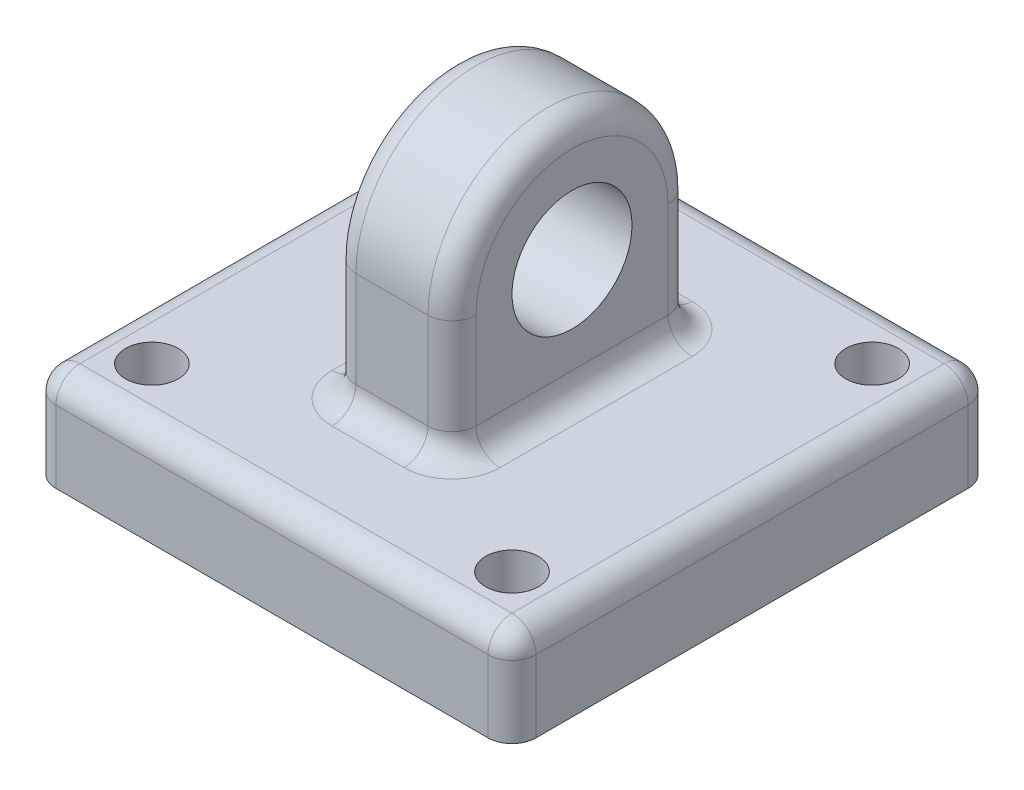
from build123d import *

# Parameters (mm, degrees)
ESQUISSE2_R             = 2.5
BOSS_EXTRU_1_DEPTH      = 2.5
ESQUISSE4_W             = 20
ESQUISSE4_H             = 20
BOSS_EXTRU_2_DEPTH      = 4
ENL_V_MAT_EXTRU_1_REACH = 6
ESQUISSE5_R             = 1.1
CONG_1_R                = 1


with BuildPart() as part:
    # Esquisse2 → Boss.-Extru.1 (new body, symmetric)
    with BuildSketch(Plane(origin=(0, 0, 0), x_dir=(0, 0, -1), z_dir=(1, 0, 0))):
        with BuildLine():
            Line((5, 0), (5, -5))
            Line((5, -5), (-5, -5))
            Line((-5, -5), (-5, 0))
            ThreePointArc((-5, 0), (0, 5), (5, 0))
        make_face()
        Circle(ESQUISSE2_R, mode=Mode.SUBTRACT)
    extrude(amount=BOSS_EXTRU_1_DEPTH, both=True)

    # Esquisse4 → Boss.-Extru.2 (add)
    with BuildSketch(Plane.XZ.offset(5)):
        Rectangle(ESQUISSE4_W, ESQUISSE4_H)
    extrude(amount=BOSS_EXTRU_2_DEPTH)

    # Esquisse5 → Enlèv. mat.-Extru.1 (cut, up to next)
    with BuildSketch(Plane(origin=(0, -5, 0), x_dir=(1, 0, 0), z_dir=(0, 1, 0)), mode=Mode.PRIVATE) as enl_v_mat_extru_1_sk1:
        with Locations(Location((7.5, -7.5, 0), (0, 0, 270))):  # turned: the seam where the file's is
            Circle(ESQUISSE5_R)
    enl_v_mat_extru_1_tool1 = extrude(enl_v_mat_extru_1_sk1.sketch, amount=-ENL_V_MAT_EXTRU_1_REACH, mode=Mode.PRIVATE) & part.part
    add(enl_v_mat_extru_1_tool1.solids().sort_by_distance((7.5, -5, 7.5))[0], mode=Mode.SUBTRACT)
    # Esquisse5 → Enlèv. mat.-Extru.1 (cut, up to next)
    with BuildSketch(Plane(origin=(0, -5, 0), x_dir=(1, 0, 0), z_dir=(0, 1, 0)), mode=Mode.PRIVATE) as enl_v_mat_extru_1_sk2:
        with Locations(Location((7.5, 7.5, 0), (0, 0, 270))):  # turned: the seam where the file's is
            Circle(ESQUISSE5_R)
    enl_v_mat_extru_1_tool2 = extrude(enl_v_mat_extru_1_sk2.sketch, amount=-ENL_V_MAT_EXTRU_1_REACH, mode=Mode.PRIVATE) & part.part
    add(enl_v_mat_extru_1_tool2.solids().sort_by_distance((7.5, -5, -7.5))[0], mode=Mode.SUBTRACT)
    # Esquisse5 → Enlèv. mat.-Extru.1 (cut, up to next)
    with BuildSketch(Plane(origin=(0, -5, 0), x_dir=(1, 0, 0), z_dir=(0, 1, 0)), mode=Mode.PRIVATE) as enl_v_mat_extru_1_sk3:
        with Locations(Location((-7.5, 7.5, 0), (0, 0, 270))):  # turned: the seam where the file's is
            Circle(ESQUISSE5_R)
    enl_v_mat_extru_1_tool3 = extrude(enl_v_mat_extru_1_sk3.sketch, amount=-ENL_V_MAT_EXTRU_1_REACH, mode=Mode.PRIVATE) & part.part
    add(enl_v_mat_extru_1_tool3.solids().sort_by_distance((-7.5, -5, -7.5))[0], mode=Mode.SUBTRACT)
    # Esquisse5 → Enlèv. mat.-Extru.1 (cut, up to next)
    with BuildSketch(Plane(origin=(0, -5, 0), x_dir=(1, 0, 0), z_dir=(0, 1, 0)), mode=Mode.PRIVATE) as enl_v_mat_extru_1_sk4:
        with Locations(Location((-7.5, -7.5, 0), (0, 0, 270))):  # turned: the seam where the file's is
            Circle(ESQUISSE5_R)
    enl_v_mat_extru_1_tool4 = extrude(enl_v_mat_extru_1_sk4.sketch, amount=-ENL_V_MAT_EXTRU_1_REACH, mode=Mode.PRIVATE) & part.part
    add(enl_v_mat_extru_1_tool4.solids().sort_by_distance((-7.5, -5, 7.5))[0], mode=Mode.SUBTRACT)

    # Congé1
    cong_1_edges = [part.edges().sort_by_distance(p)[0] for p in [
        (2.5, -5, 0),
        (2.5, -2.5, -5),
        (-10, -5, 0),
        (-10, -7, 10),
        (0, -5, -10),
        (-10, -7, -10),
        (10, -5, 0),
        (10, -7, -10),
        (0, -5, 10),
        (10, -7, 10),
        (2.5, 5, 0),
        (-2.5, -2.5, -5),
        (-2.5, -5, 0),
        (-2.5, -2.5, 5),
        (-2.5, 5, 0),
        (0, -5, -5),
        (0, -5, 5),
        (2.5, -2.5, 5),
    ]]
    fillet(cong_1_edges, radius=CONG_1_R)


solid = part.part
